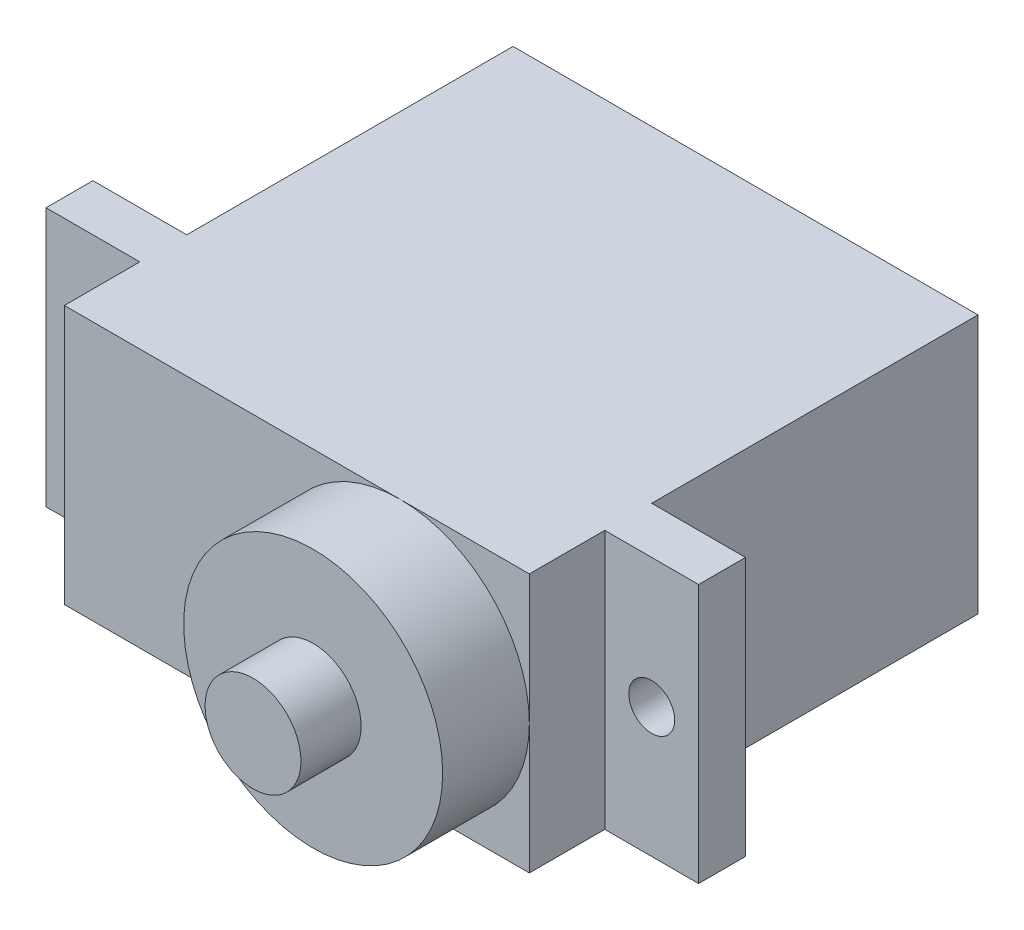
from build123d import *

# Parameters (mm, degrees)
SKETCH1_W           = 22.8
SKETCH1_H           = 12.7
BODY_DEPTH          = 22
SKETCH2_W           = 4.6
SKETCH2_H           = 12.7
SKETCH2_R           = 1.125
BOSS_EXTRUDE2_DEPTH = 2.3
SKETCH3_R           = 2.35
BOSS_EXTRUDE3_DEPTH = 7.2
SKETCH4_R           = 6.35
BOSS_EXTRUDE4_DEPTH = 4.25


with BuildPart() as part:
    # Sketch1 → Body (new body)
    with BuildSketch(Plane.XY):
        Rectangle(SKETCH1_W, SKETCH1_H)
    extrude(amount=BODY_DEPTH)

    # Sketch2 → Boss-Extrude2 (add)
    with BuildSketch(Plane(origin=(0, 0, 16), x_dir=(-1, 0, 0), z_dir=(0, 0, -1))):
        with Locations((13.7, 0)):
            Rectangle(SKETCH2_W, SKETCH2_H)
        with Locations((13.7, 0)):
            Circle(SKETCH2_R, mode=Mode.SUBTRACT)
        with Locations((-13.7, 0)):
            Rectangle(SKETCH2_W, SKETCH2_H)
        with Locations((-13.7, 0)):
            Circle(SKETCH2_R, mode=Mode.SUBTRACT)
    extrude(amount=-BOSS_EXTRUDE2_DEPTH)

    # Sketch3 → Boss-Extrude3 (add)
    with BuildSketch(Plane.XY.offset(22)):
        with Locations((5.05, 0)):
            Circle(SKETCH3_R)
    extrude(amount=BOSS_EXTRUDE3_DEPTH)

    # Sketch4 → Boss-Extrude4 (add)
    with BuildSketch(Plane.XY.offset(22)):
        with Locations((5.05, 0)):
            Circle(SKETCH4_R)
    extrude(amount=BOSS_EXTRUDE4_DEPTH)


solid = part.part
